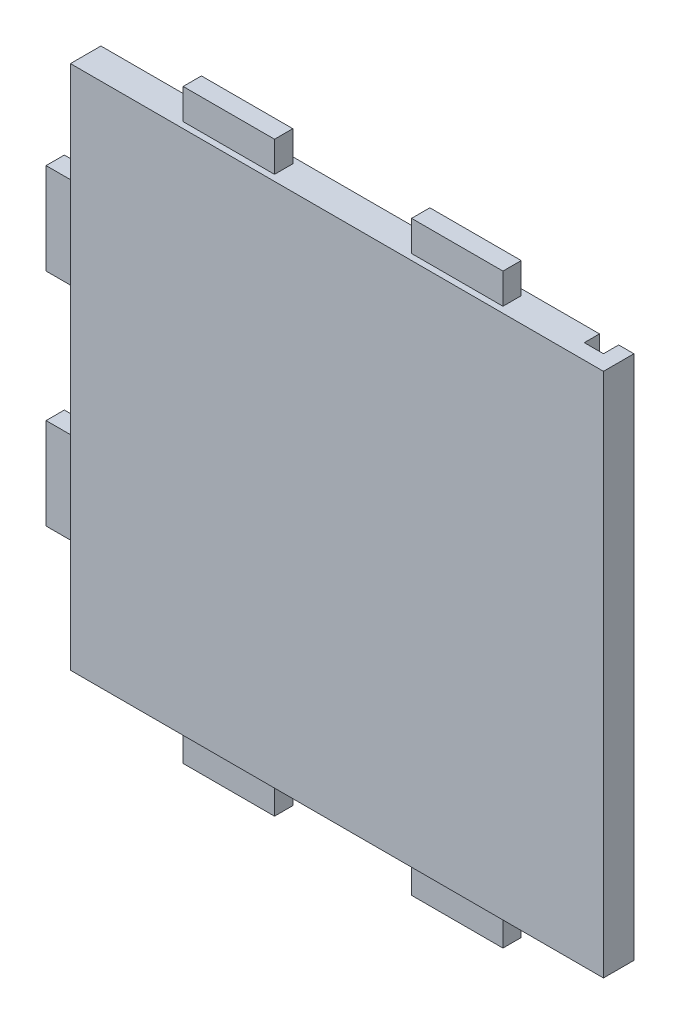
from build123d import *

# Parameters (mm, degrees)
ESBO_O1_W                = 175
ESBO_O1_H                = 172.5
RESSALTO_EXTRUS_O1_DEPTH = 10
ESBO_O5_W                = 30
ESBO_O5_H                = 6
RESSALTO_EXTRUS_O5_DEPTH = 10
ESBO_O6_W                = 6
ESBO_O6_H                = 30
RESSALTO_EXTRUS_O6_DEPTH = 10
ESBO_O7_W                = 30
ESBO_O7_H                = 6
RESSALTO_EXTRUS_O7_DEPTH = 10
ESBO_O8_W                = 6.3
ESBO_O8_H                = 172.5
CORTE_EXTRUS_O1_DEPTH    = 5
ESBO_O9_R                = 1.5
CORTE_EXTRUS_O2_DEPTH    = 8
ESBO_O10_R               = 1.5
CORTE_EXTRUS_O3_DEPTH    = 8


with BuildPart() as part:
    # Esboço1 → Ressalto-extrusão1 (new body)
    with BuildSketch(Plane.XY):
        Rectangle(ESBO_O1_W, ESBO_O1_H)
    extrude(amount=RESSALTO_EXTRUS_O1_DEPTH)

    # Esboço5 → Ressalto-extrusão5 (add)
    with BuildSketch(Plane(origin=(0, 86.25, 0), x_dir=(1, 0, 0), z_dir=(0, 1, 0))):
        with Locations((-37.5, -5)):
            Rectangle(ESBO_O5_W, ESBO_O5_H)
        with Locations((37.5, -5)):
            Rectangle(ESBO_O5_W, ESBO_O5_H)
    extrude(amount=RESSALTO_EXTRUS_O5_DEPTH)

    # Esboço6 → Ressalto-extrusão6 (add)
    with BuildSketch(Plane.ZY.offset(87.5)):
        with Locations((5, 36.25)):
            Rectangle(ESBO_O6_W, ESBO_O6_H)
        with Locations((5, -36.25)):
            Rectangle(ESBO_O6_W, ESBO_O6_H)
    extrude(amount=RESSALTO_EXTRUS_O6_DEPTH)

    # Esboço7 → Ressalto-extrusão7 (add)
    with BuildSketch(Plane.XZ.offset(86.25)):
        with Locations((-37.5, 5)):
            Rectangle(ESBO_O7_W, ESBO_O7_H)
        with Locations((37.5, 5)):
            Rectangle(ESBO_O7_W, ESBO_O7_H)
    extrude(amount=RESSALTO_EXTRUS_O7_DEPTH)

    # Esboço8 → Corte-extrusão1 (cut)
    with BuildSketch(Plane(origin=(0, 0, 0), x_dir=(-1, 0, 0), z_dir=(0, 0, -1))):
        with Locations((-79.35, 0)):
            Rectangle(ESBO_O8_W, ESBO_O8_H)
    extrude(amount=-CORTE_EXTRUS_O1_DEPTH, mode=Mode.SUBTRACT)

    # Esboço9 → Corte-extrusão2 (cut)
    with BuildSketch(Plane.ZY.offset(87.5)):
        with Locations((5, -71.25)):
            Circle(ESBO_O9_R)
    extrude(amount=-CORTE_EXTRUS_O2_DEPTH, mode=Mode.SUBTRACT)

    # Esboço10 → Corte-extrusão3 (cut)
    with BuildSketch(Plane.XZ.offset(86.25)):
        with Locations((65, 5)):
            Circle(ESBO_O10_R)
    extrude(amount=-CORTE_EXTRUS_O3_DEPTH, mode=Mode.SUBTRACT)


solid = part.part
